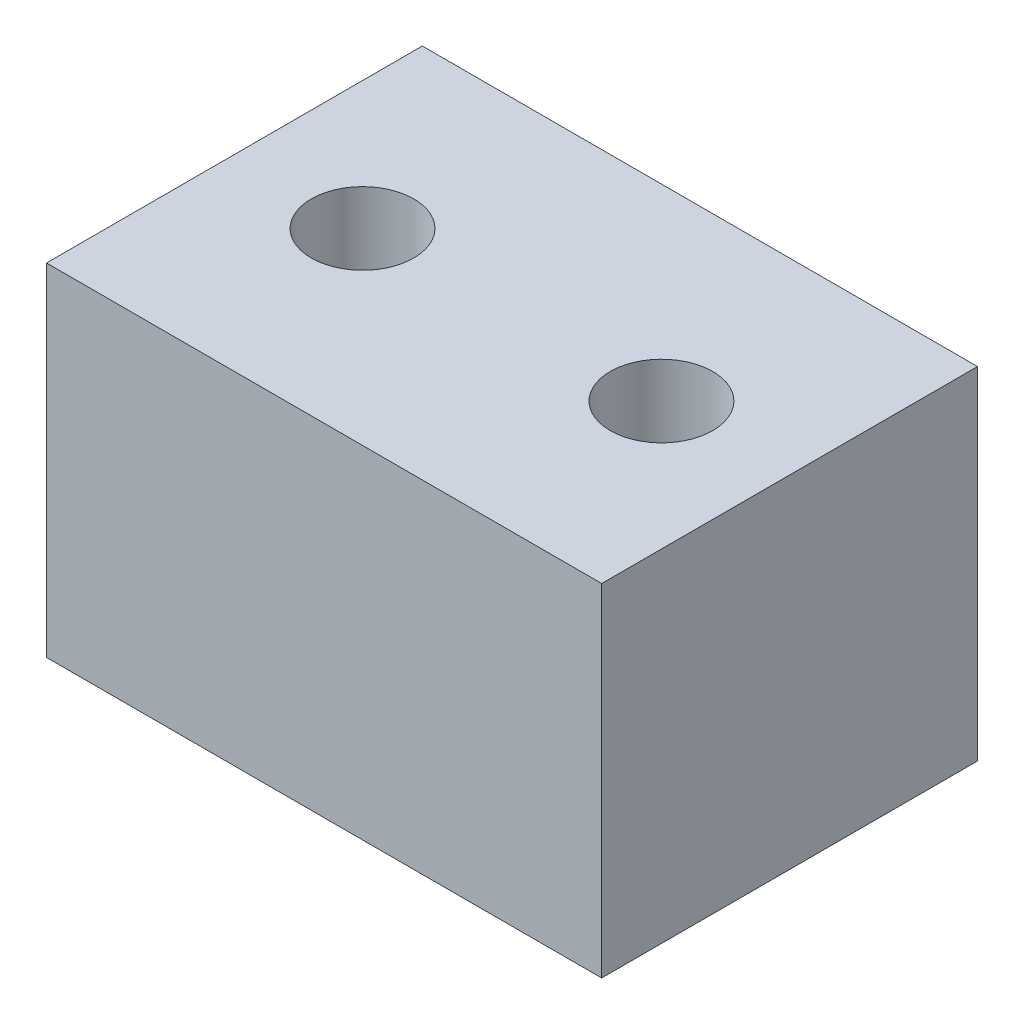
from build123d import *

# Parameters (mm, degrees)
SKETCH1_W           = 65
SKETCH1_H           = 44
SKETCH1_R           = 6
BOSS_EXTRUDE1_DEPTH = 40


with BuildPart() as part:
    # Sketch1 → Boss-Extrude1 (new body)
    with BuildSketch(Plane(origin=(0, 0, 0), x_dir=(1, 0, 0), z_dir=(0, 1, 0))):
        with Locations((-19.790994624, 6.628024194)):
            Rectangle(SKETCH1_W, SKETCH1_H)
        with Locations((-2.290994624, 6.628024194)):
            Circle(SKETCH1_R, mode=Mode.SUBTRACT)
        with Locations((-37.290994624, 6.628024194)):
            Circle(SKETCH1_R, mode=Mode.SUBTRACT)
    extrude(amount=BOSS_EXTRUDE1_DEPTH)


solid = part.part
